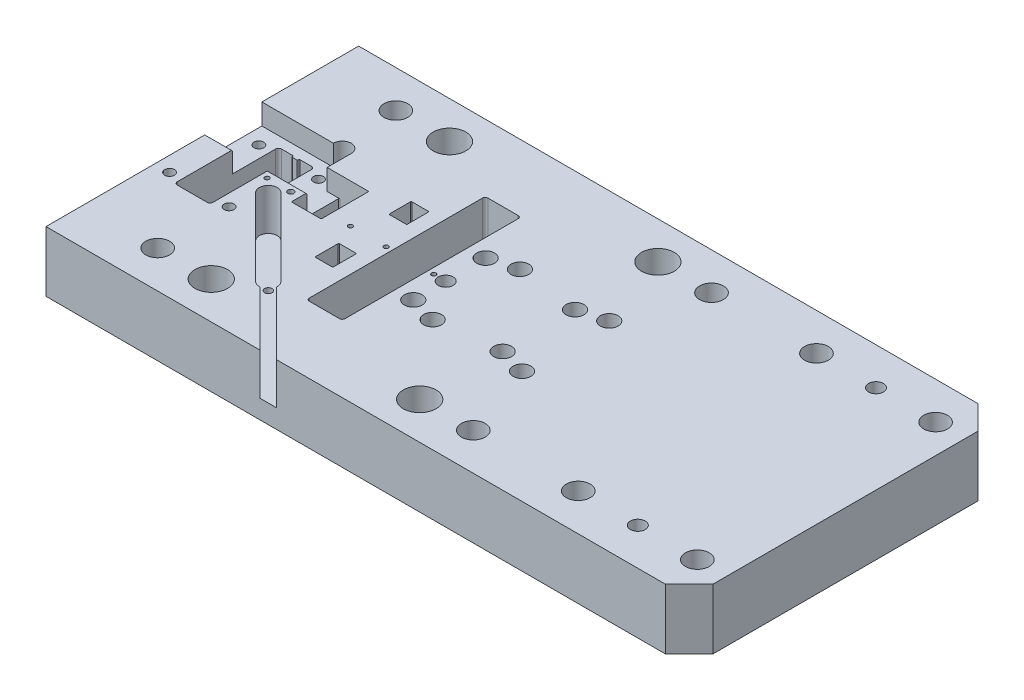
from build123d import *

# Parameters (mm, degrees)
SKETCH1_W                                           = 216
SKETCH1_H                                           = 20.3
EXTRUDE1_DEPTH                                      = 52.5
CBORE_FOR_M6_HEX_SOCKET_HEAD_CAP_SCREW1_D           = 6.4
CBORE_FOR_M6_HEX_SOCKET_HEAD_CAP_SCREW1_CBORE_D     = 11
CBORE_FOR_M6_HEX_SOCKET_HEAD_CAP_SCREW1_CBORE_DEPTH = 11
LPATTERN5_COUNT                                     = 2
LPATTERN5_PITCH                                     = 70
LPATTERN5_COUNT_DIR2                                = 2
LPATTERN5_PITCH_DIR2                                = 80
HOLE1_D                                             = 8
LPATTERN6_COUNT                                     = 2
LPATTERN6_PITCH                                     = 106
LPATTERN6_COUNT_DIR2                                = 2
LPATTERN6_PITCH_DIR2                                = 80
HOLE2_D                                             = 6
CUT_EXTRUDE2_DEPTH                                  = 21.3
HOLE3_D                                             = 5
HOLE3_DEPTH                                         = 100
HOLE3_CBORE_D                                       = 8
HOLE3_CBORE_DEPTH                                   = 5
CUT_EXTRUDE3_DEPTH                                  = 21.3
CUT_EXTRUDE4_DEPTH                                  = 21.3
CUT_EXTRUDE5_DEPTH                                  = 21.3
SKETCH26_W                                          = 34.25
SKETCH26_H                                          = 10.8
CUT_EXTRUDE6_DEPTH                                  = 7
CUT_EXTRUDE7_DEPTH                                  = 21.3
CHAMFER2_SIZE                                       = 0.3
HOLE4_D                                             = 1.5
HOLE4_DEPTH                                         = 3
HOLE4_TIP                                           = 0.433012702
CUT_EXTRUDE9_DEPTH                                  = 7
M4_TAPPED_HOLE1_D                                   = 3.3
M4_TAPPED_HOLE1_DEPTH                               = 15
M4_TAPPED_HOLE1_TIP                                 = 0.991420021
M4_TAPPED_HOLE2_D                                   = 3.3
M4_TAPPED_HOLE2_DEPTH                               = 15
M4_TAPPED_HOLE2_TIP                                 = 0.991420021
CHAMFER3_SIZE                                       = 8
HOLE5_D                                             = 8
HOLE5_DEPTH                                         = 100
M6_TAPPED_HOLE2_D                                   = 5
HOLE6_D                                             = 2
HOLE6_DEPTH                                         = 5
CUT_EXTRUDE10_DEPTH                                 = 14
M3_TAPPED_HOLE1_D                                   = 2.5
M3_TAPPED_HOLE1_DEPTH                               = 7.5
M3_TAPPED_HOLE1_TIP                                 = 0.751075774


with BuildPart() as part:
    # Sketch1 → Extrude1 (new body, symmetric)
    with BuildSketch(Plane.XY):
        with Locations((30, 10.15)):
            Rectangle(SKETCH1_W, SKETCH1_H)
    extrude(amount=EXTRUDE1_DEPTH, both=True)

    # CBORE for M6 Hex Socket Head Cap Screw1 (through all)
    with Locations(Plane(origin=(0, 20.3, 0), x_dir=(-1, 0, 0), z_dir=(0, 1, 0))):
        with Locations((35, -40)):
            cbore_for_m6_hex_socket_head_cap_screw1 = CounterBoreHole(CBORE_FOR_M6_HEX_SOCKET_HEAD_CAP_SCREW1_D / 2, CBORE_FOR_M6_HEX_SOCKET_HEAD_CAP_SCREW1_CBORE_D / 2, CBORE_FOR_M6_HEX_SOCKET_HEAD_CAP_SCREW1_CBORE_DEPTH)

    # LPattern5: CBORE for M6 Hex Socket Head Cap Screw1 2 × 2
    with Locations(*[(i * LPATTERN5_PITCH, 0, j * LPATTERN5_PITCH_DIR2) for i in range(LPATTERN5_COUNT) for j in range(LPATTERN5_COUNT_DIR2) if (i, j) != (0, 0)]):
        add(cbore_for_m6_hex_socket_head_cap_screw1, mode=Mode.SUBTRACT)

    # Hole1 (through all)
    with Locations(Plane(origin=(0, 20.3, 0), x_dir=(-1, 0, 0), z_dir=(0, 1, 0))):
        with Locations((53, -40)):
            hole1 = Hole(HOLE1_D / 2)

    # LPattern6: Hole1 2 × 2
    with Locations(*[(i * LPATTERN6_PITCH, 0, j * LPATTERN6_PITCH_DIR2) for i in range(LPATTERN6_COUNT) for j in range(LPATTERN6_COUNT_DIR2) if (i, j) != (0, 0)]):
        add(hole1, mode=Mode.SUBTRACT)

    # Hole2 (through all)
    with Locations(Plane(origin=(0, 20.3, 0), x_dir=(-1, 0, 0), z_dir=(0, 1, 0))):
        with Locations((-35, 12.15), (-35, -12.15), (-5, -12.15), (-5, 12.15), (-14, -14.65), (-14, 14.65), (-44, 14.65), (-44, -14.65)):
            Hole(HOLE2_D / 2)

    # Sketch20 → Cut-Extrude2 (cut, through all)
    with BuildSketch(Plane(origin=(0, 20.3, 0), x_dir=(1, 0, 0), z_dir=(0, 1, 0))):
        with BuildLine():
            Line((-1.933012804, 30), (-12.066987196, 30))
            ThreePointArc((-12.066987196, 30), (-12.726726877, 29.726726877), (-13, 29.066987196))
            Line((-13, 29.066987196), (-13, -29.066987196))
            ThreePointArc((-13, -29.066987196), (-12.726726877, -29.726726877), (-12.066987196, -30))
            Line((-12.066987196, -30), (-1.933012804, -30))
            ThreePointArc((-1.933012804, -30), (-1.273273123, -29.726726877), (-1, -29.066987196))
            Line((-1, -29.066987196), (-1, 29.066987196))
            ThreePointArc((-1, 29.066987196), (-1.273273123, 29.726726877), (-1.933012804, 30))
        make_face()
    extrude(amount=-CUT_EXTRUDE2_DEPTH, mode=Mode.SUBTRACT)

    # Hole3
    with Locations(Plane(origin=(0, 0, 0), x_dir=(-1, 0, 0), z_dir=(0, -1, 0))):
        with Locations((-5, -1.269390874)):
            CounterBoreHole(HOLE3_D / 2, HOLE3_CBORE_D / 2, HOLE3_CBORE_DEPTH, depth=HOLE3_DEPTH)

    # Sketch23 → Cut-Extrude3 (cut, through all)
    with BuildSketch(Plane(origin=(0, 20.3, 0), x_dir=(1, 0, 0), z_dir=(0, 1, 0))):
        with BuildLine():
            Line((-18.25, -8.195359581), (-23.75, -8.195359581))
            ThreePointArc((-23.75, -8.195359581), (-23.926776695, -8.268582886), (-24, -8.445359581))
            Line((-24, -8.445359581), (-24, -15.945359581))
            ThreePointArc((-24, -15.945359581), (-23.926776695, -16.122136276), (-23.75, -16.195359581))
            Line((-23.75, -16.195359581), (-18.25, -16.195359581))
            ThreePointArc((-18.25, -16.195359581), (-18.073223305, -16.122136276), (-18, -15.945359581))
            Line((-18, -15.945359581), (-18, -8.445359581))
            ThreePointArc((-18, -8.445359581), (-18.073223305, -8.268582886), (-18.25, -8.195359581))
        make_face()
        with BuildLine():
            Line((-18.25, 16.15), (-23.75, 16.15))
            ThreePointArc((-23.75, 16.15), (-23.926776695, 16.076776695), (-24, 15.9))
            Line((-24, 15.9), (-24, 8.9))
            ThreePointArc((-24, 8.9), (-23.926776695, 8.723223305), (-23.75, 8.65))
            Line((-23.75, 8.65), (-18.25, 8.65))
            ThreePointArc((-18.25, 8.65), (-18.073223305, 8.723223305), (-18, 8.9))
            Line((-18, 8.9), (-18, 15.9))
            ThreePointArc((-18, 15.9), (-18.073223305, 16.076776695), (-18.25, 16.15))
        make_face()
    extrude(amount=-CUT_EXTRUDE3_DEPTH, mode=Mode.SUBTRACT)

    # Sketch24 → Cut-Extrude4 (cut, through all)
    with BuildSketch(Plane(origin=(0, 20.3, 0), x_dir=(1, 0, 0), z_dir=(0, 1, 0))):
        with BuildLine():
            Line((-34.25, 11.904640419), (-39, 11.904640419))
            Line((-39, 11.904640419), (-39, -4.095359581))
            Line((-39, -4.095359581), (-34.25, -4.095359581))
            ThreePointArc((-34.25, -4.095359581), (-34.073223305, -4.022136276), (-34, -3.845359581))
            Line((-34, -3.845359581), (-34, 11.654640419))
            ThreePointArc((-34, 11.654640419), (-34.073223305, 11.831417114), (-34.25, 11.904640419))
        make_face()
    extrude(amount=-CUT_EXTRUDE4_DEPTH, mode=Mode.SUBTRACT)

    # Sketch25 → Cut-Extrude5 (cut, through all)
    with BuildSketch(Plane(origin=(0, 20.3, 0), x_dir=(1, 0, 0), z_dir=(0, 1, 0))):
        with BuildLine():
            Line((-43.75, -4.095359581), (-39, -4.095359581))
            Line((-39, -4.095359581), (-39, 11.904640419))
            Line((-39, 11.904640419), (-43.75, 11.904640419))
            ThreePointArc((-43.75, 11.904640419), (-43.926776695, 11.831417114), (-44, 11.654640419))
            Line((-44, 11.654640419), (-44, -3.845359581))
            ThreePointArc((-44, -3.845359581), (-43.926776695, -4.022136276), (-43.75, -4.095359581))
        make_face()
    extrude(amount=-CUT_EXTRUDE5_DEPTH, mode=Mode.SUBTRACT)

    # Sketch26 → Cut-Extrude6 (cut)
    with BuildSketch(Plane(origin=(0, 20.3, 0), x_dir=(1, 0, 0), z_dir=(0, 1, 0))):
        with Locations((-60.875, 6.504640419)):
            Rectangle(SKETCH26_W, SKETCH26_H)
    extrude(amount=-CUT_EXTRUDE6_DEPTH, mode=Mode.SUBTRACT)

    # Sketch27 → Cut-Extrude7 (cut, through all)
    with BuildSketch(Plane(origin=(0, 20.3, 0), x_dir=(1, 0, 0), z_dir=(0, 1, 0))):
        with BuildLine():
            Line((-64.25, 16.604640419), (-68, 16.604640419))
            ThreePointArc((-68, 16.604640419), (-68.707106781, 16.3117472), (-69, 15.604640419))
            Line((-69, 15.604640419), (-69, -17.395359581))
            ThreePointArc((-69, -17.395359581), (-68.707106781, -18.102466362), (-68, -18.395359581))
            Line((-68, -18.395359581), (-58, -18.395359581))
            ThreePointArc((-58, -18.395359581), (-57.292893219, -18.102466362), (-57, -17.395359581))
            Line((-57, -17.395359581), (-57, 15.604640419))
            ThreePointArc((-57, 15.604640419), (-57.292893219, 16.3117472), (-58, 16.604640419))
            Line((-58, 16.604640419), (-61.75, 16.604640419))
            ThreePointArc((-61.75, 16.604640419), (-61.926776695, 16.531417114), (-62, 16.354640419))
            Line((-62, 16.354640419), (-62, 16.254640419))
            ThreePointArc((-62, 16.254640419), (-62.073223305, 16.077863724), (-62.25, 16.004640419))
            Line((-62.25, 16.004640419), (-63.75, 16.004640419))
            ThreePointArc((-63.75, 16.004640419), (-63.926776695, 16.077863724), (-64, 16.254640419))
            Line((-64, 16.254640419), (-64, 16.354640419))
            ThreePointArc((-64, 16.354640419), (-64.073223305, 16.531417114), (-64.25, 16.604640419))
        make_face()
    extrude(amount=-CUT_EXTRUDE7_DEPTH, mode=Mode.SUBTRACT)

    # Chamfer2
    chamfer2_edges = [part.edges().sort_by_distance(p)[0] for p in [
        (-73.5, 20.3, -1.104640419),
        (-50.5, 20.3, -1.104640419),
    ]]
    chamfer(chamfer2_edges, length=CHAMFER2_SIZE)

    # Hole4
    with Locations(Plane(origin=(0, 20.3, 0), x_dir=(-1, 0, 0), z_dir=(0, 1, 0))):
        with Locations((-1, 1.269390874), (15, 1.269390874), (27, 1.269390874), (55, 1.269390874)):
            Hole(HOLE4_D / 2, depth=HOLE4_DEPTH)
            with Locations((0, 0, -(HOLE4_DEPTH + HOLE4_TIP / 2))):  # 120° drill point
                Cone(0, HOLE4_D / 2, HOLE4_TIP, mode=Mode.SUBTRACT)

    # Sketch30 → Cut-Extrude9 (cut)
    with BuildSketch(Plane(origin=(0, 20.3, 0), x_dir=(1, 0, 0), z_dir=(0, 1, 0))):
        with BuildLine():
            Line((-78, 11.904640419), (-48, 11.904640419))
            Line((-48, 11.904640419), (-48, 20))
            ThreePointArc((-48, 20), (-51, 23), (-54, 20))
            Line((-54, 20), (-78, 20))
            Line((-78, 20), (-78, 11.904640419))
        make_face()
    extrude(amount=-CUT_EXTRUDE9_DEPTH, mode=Mode.SUBTRACT)

    # M4 Tapped Hole1
    with Locations(Plane(origin=(0, 20.3, 0), x_dir=(1, 0, 0), z_dir=(0, 1, 0))):
        with Locations((-53, -16), (-73, -16)):
            Hole(M4_TAPPED_HOLE1_D / 2, depth=M4_TAPPED_HOLE1_DEPTH)
            with Locations((0, 0, -(M4_TAPPED_HOLE1_DEPTH + M4_TAPPED_HOLE1_TIP / 2))):  # 118° drill point
                Cone(0, M4_TAPPED_HOLE1_D / 2, M4_TAPPED_HOLE1_TIP, mode=Mode.SUBTRACT)

    # M4 Tapped Hole2
    with Locations(Plane(origin=(0, 13.3, 0), x_dir=(1, 0, 0), z_dir=(0, 1, 0))):
        with Locations((-73, 14), (-53, 14)):
            Hole(M4_TAPPED_HOLE2_D / 2, depth=M4_TAPPED_HOLE2_DEPTH)
            with Locations((0, 0, -(M4_TAPPED_HOLE2_DEPTH + M4_TAPPED_HOLE2_TIP / 2))):  # 118° drill point
                Cone(0, M4_TAPPED_HOLE2_D / 2, M4_TAPPED_HOLE2_TIP, mode=Mode.SUBTRACT)

    # Chamfer3
    chamfer3_edges = [part.edges().sort_by_distance(p)[0] for p in [
        (138, 10.15, 52.5),
        (138, 10.15, -52.5),
    ]]
    chamfer(chamfer3_edges, length=CHAMFER3_SIZE)

    # Hole5
    with Locations(Plane(origin=(0, 20.3, 0), x_dir=(1, 0, 0), z_dir=(0, 1, 0))):
        with Locations((88.25, 40), (128.25, 40), (88.25, -40), (128.25, -40)):
            Hole(HOLE5_D / 2, depth=HOLE5_DEPTH)

    # M6 Tapped Hole2 (through all)
    with Locations(Plane(origin=(0, 20.3, 0), x_dir=(1, 0, 0), z_dir=(0, 1, 0))):
        with Locations((108.25, 40), (108.25, -40)):
            Hole(M6_TAPPED_HOLE2_D / 2)

    # Hole6
    with Locations(Plane(origin=(0, 20.3, 0), x_dir=(1, 0, 0), z_dir=(0, 1, 0))):
        with Locations((-47, -1.269390874)):
            Hole(HOLE6_D / 2, depth=HOLE6_DEPTH)

    # Sketch41 → Cut-Extrude10 (cut)
    with BuildSketch(Plane(origin=(0, 20.3, 0), x_dir=(1, 0, 0), z_dir=(0, 1, 0))):
        with BuildLine():
            Line((-52.653265146, -7.448877258), (-26.843867632, -33.258274771))
            ThreePointArc((-26.843867632, -33.258274771), (-25.785337315, -33.943332709), (-24.539076694, -34.134710012))
            Line((-24.539076694, -34.134710012), (-3.163472859, -55.510313847))
            Line((-3.163472859, -55.510313847), (-0.335045734, -52.681886722))
            Line((-0.335045734, -52.681886722), (-21.710649569, -31.306282887))
            ThreePointArc((-21.710649569, -31.306282887), (-21.902026872, -30.060022265), (-22.587084809, -29.001491949))
            Line((-22.587084809, -29.001491949), (-48.396482323, -3.192094435))
            ThreePointArc((-48.396482323, -3.192094435), (-52.653265146, -3.192094435), (-52.653265146, -7.448877258))
        make_face()
    extrude(amount=-CUT_EXTRUDE10_DEPTH, mode=Mode.SUBTRACT)

    # M3 Tapped Hole1
    with Locations(Plane(origin=(0, 6.3, 0), x_dir=(1, 0, 0), z_dir=(0, 1, 0))):
        with Locations((-36.02918472, -19.816174861)):
            Hole(M3_TAPPED_HOLE1_D / 2, depth=M3_TAPPED_HOLE1_DEPTH)
            with Locations((0, 0, -(M3_TAPPED_HOLE1_DEPTH + M3_TAPPED_HOLE1_TIP / 2))):  # 118° drill point
                Cone(0, M3_TAPPED_HOLE1_D / 2, M3_TAPPED_HOLE1_TIP, mode=Mode.SUBTRACT)


solid = part.part
